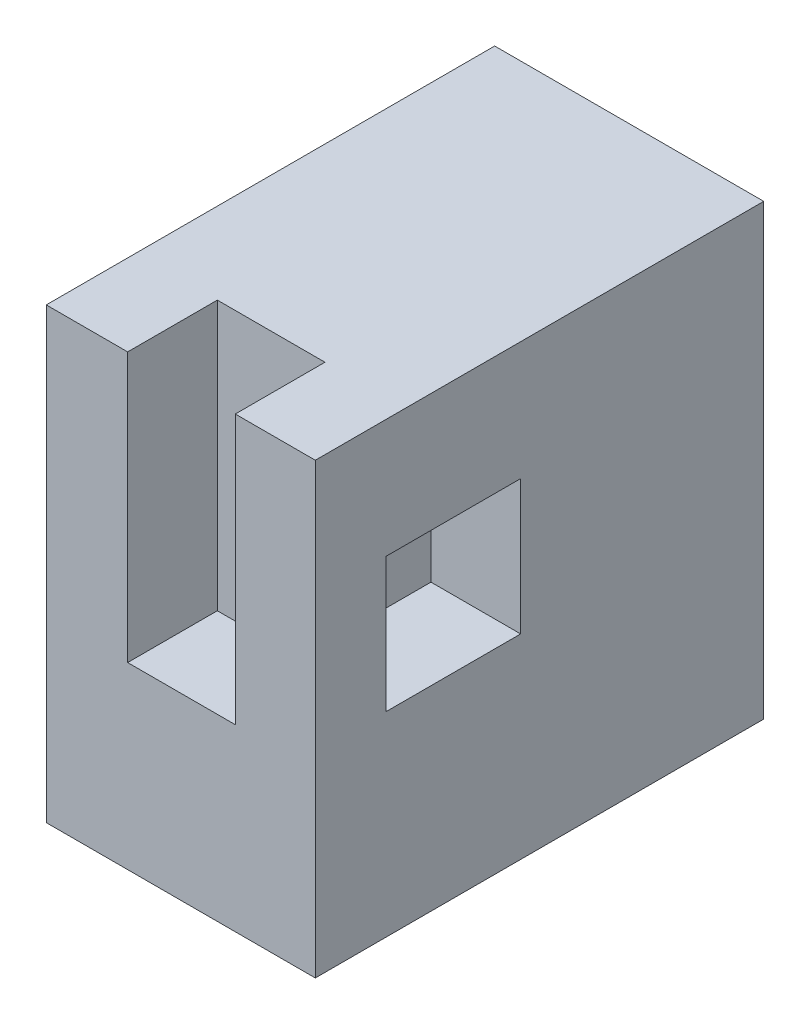
from build123d import *

# Parameters (mm, degrees)
ESQUISSE1_W             = 30
ESQUISSE1_H             = 50
BOSS_EXTRU_1_DEPTH      = 50
ESQUISSE2_W             = 12
ESQUISSE2_H             = 30
ENL_V_MAT_EXTRU_1_DEPTH = 10
ESQUISSE4_W             = 15
ESQUISSE4_H             = 15
ENL_V_MAT_EXTRU_2_DEPTH = 10


with BuildPart() as part:
    # Esquisse1 → Boss.-Extru.1 (new body)
    with BuildSketch(Plane.XY):
        with Locations((-62.240250499, -15.911393152)):
            Rectangle(ESQUISSE1_W, ESQUISSE1_H)
    extrude(amount=BOSS_EXTRU_1_DEPTH)

    # Esquisse2 → Enlèv. mat.-Extru.1 (cut)
    with BuildSketch(Plane.XY.offset(50)):
        with Locations((-62.165259594, -5.911393152)):
            Rectangle(ESQUISSE2_W, ESQUISSE2_H)
    extrude(amount=-ENL_V_MAT_EXTRU_1_DEPTH, mode=Mode.SUBTRACT)

    # Esquisse4 → Enlèv. mat.-Extru.2 (cut)
    with BuildSketch(Plane(origin=(-47.240250499, 0, 0), x_dir=(0, 0, -1), z_dir=(1, 0, 0))):
        with Locations((-34.604526696, -11.633120899)):
            Rectangle(ESQUISSE4_W, ESQUISSE4_H)
    extrude(amount=-ENL_V_MAT_EXTRU_2_DEPTH, mode=Mode.SUBTRACT)


solid = part.part
